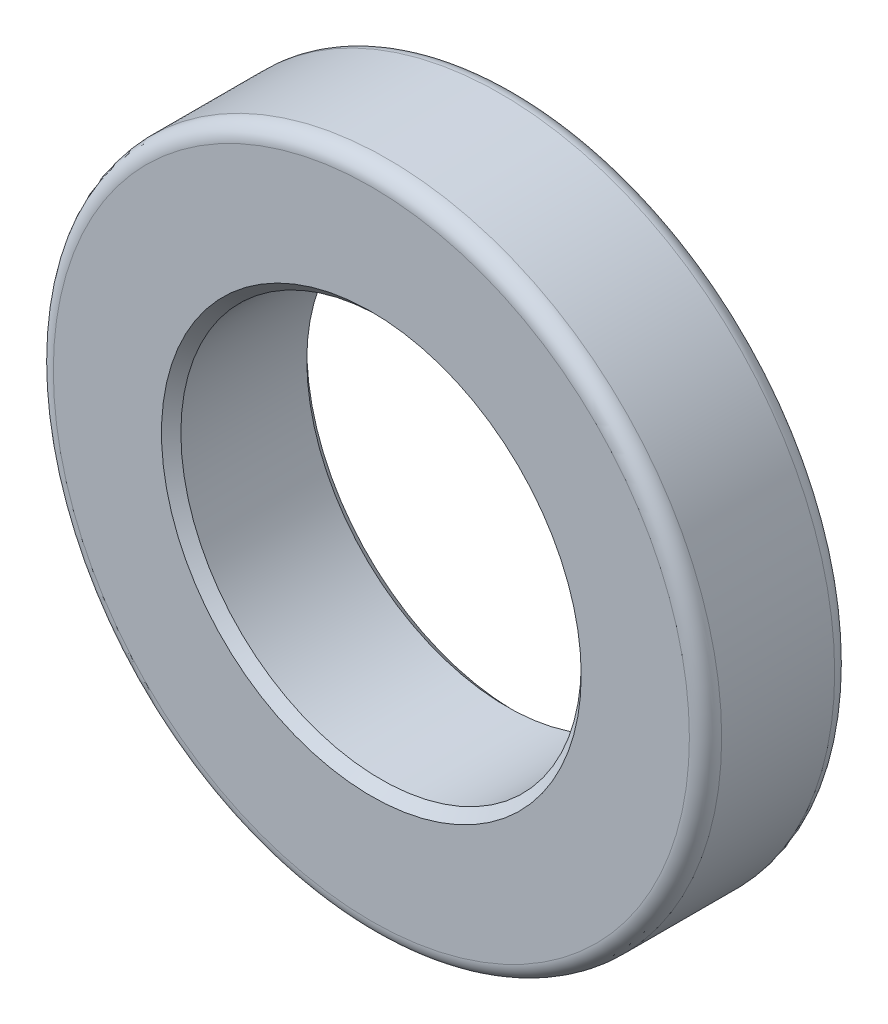
from build123d import *

# Parameters (mm, degrees)
SKETCH1_R           = 2.6289
SKETCH1_R_2         = 1.5748
BOSS_EXTRUDE1_DEPTH = 1.143
FILLET1_R           = 0.127
CHAMFER1_SIZE       = 0.0762


with BuildPart() as part:
    # Sketch1 → Boss-Extrude1 (new body)
    with BuildSketch(Plane.XY):
        Circle(SKETCH1_R)
        Circle(SKETCH1_R_2, mode=Mode.SUBTRACT)
    extrude(amount=BOSS_EXTRUDE1_DEPTH)

    # Fillet1
    fillet1_edges = [part.edges().sort_by_distance(p)[0] for p in [
        (-2.6289, 0, 0),
        (-2.6289, 0, 1.143),
    ]]
    fillet(fillet1_edges, radius=FILLET1_R)

    # Chamfer1
    chamfer1_edges = [part.edges().sort_by_distance(p)[0] for p in [
        (-1.5748, 0, 0),
        (-1.5748, 0, 1.143),
    ]]
    chamfer(chamfer1_edges, length=CHAMFER1_SIZE)


solid = part.part
